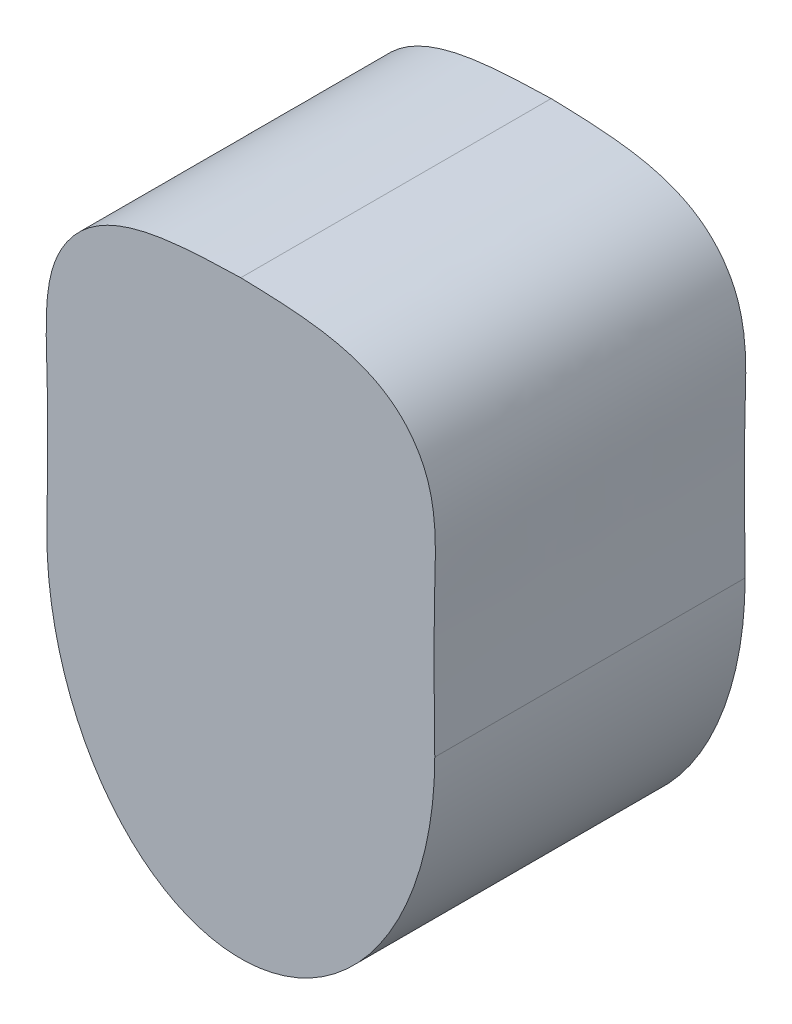
from build123d import *

# Parameters (mm, degrees)
EXTRUDE1_DEPTH = 80


with BuildPart() as part:
    # Sketch1 → Extrude1 (new body)
    with BuildSketch(Plane.XY):
        with BuildLine():
            add(Edge.make_bspline(
                [(-50, 0), (-50, -70), (0, -70), (50, -70), (50, 0)],
                knots=[1.570796327, 1.570796327, 1.570796327, 3.141592654, 3.141592654, 4.71238898, 4.71238898, 4.71238898], degree=2, weights=[1, 0.707106781, 1, 0.707106781, 1]))
            add(Edge.make_bspline(
                [(50, 0), (49.82427605, 12.441117307), (49.526019159, 33.557470374), (50.883194218, 58.606249093), (36.031869096, 80.990144921), (16.672180555, 81.541179155), (0, 82.01571893)],
                knots=[0, 0, 0, 0, 0.326036361, 0.553382686, 0.61538201, 1, 1, 1, 1], degree=3))
            add(Edge.make_bspline(
                [(-50, 0), (-49.82427605, 12.441117307), (-49.526019159, 33.557470374), (-50.883194218, 58.606249093), (-36.031869096, 80.990144921), (-16.672180555, 81.541179155), (0, 82.01571893)],
                knots=[0, 0, 0, 0, 0.326036361, 0.553382686, 0.61538201, 1, 1, 1, 1], degree=3))
        make_face()
    extrude(amount=EXTRUDE1_DEPTH)


solid = part.part
